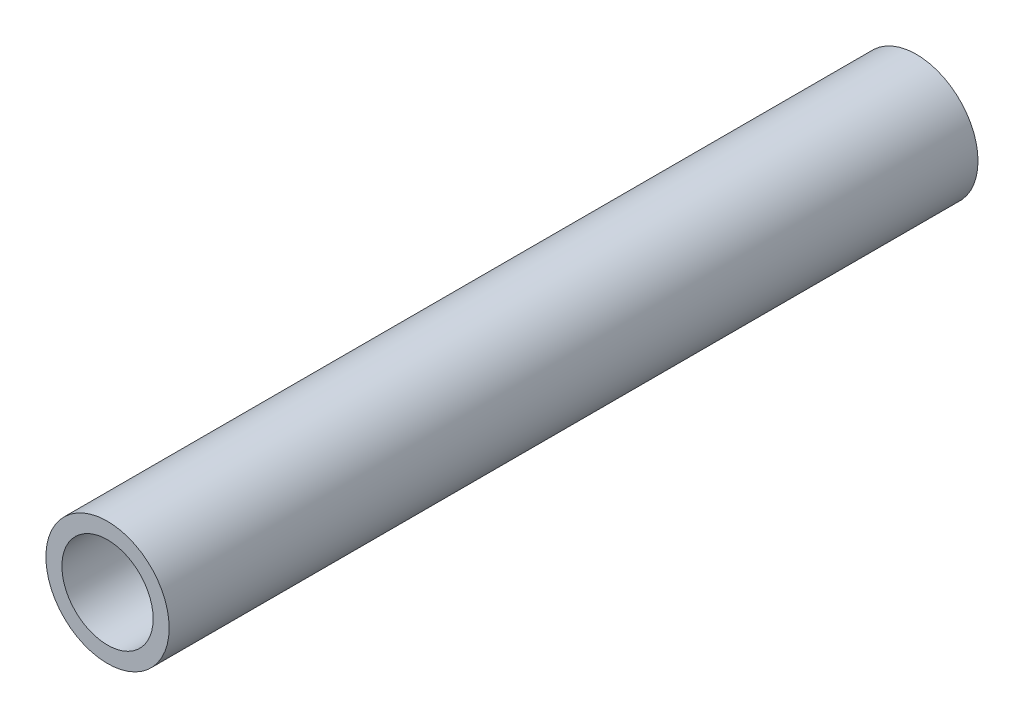
from build123d import *

# Parameters (mm, degrees)
SKETCH1_R           = 10.668
SKETCH1_R_2         = 7.8994
EXTRUDE_THIN1_DEPTH = 70


with BuildPart() as part:
    # Sketch1 → Extrude-Thin1 (new body, symmetric)
    with BuildSketch(Plane.XY):
        Circle(SKETCH1_R)
        Circle(SKETCH1_R_2, mode=Mode.SUBTRACT)
    extrude(amount=EXTRUDE_THIN1_DEPTH, both=True)


solid = part.part
